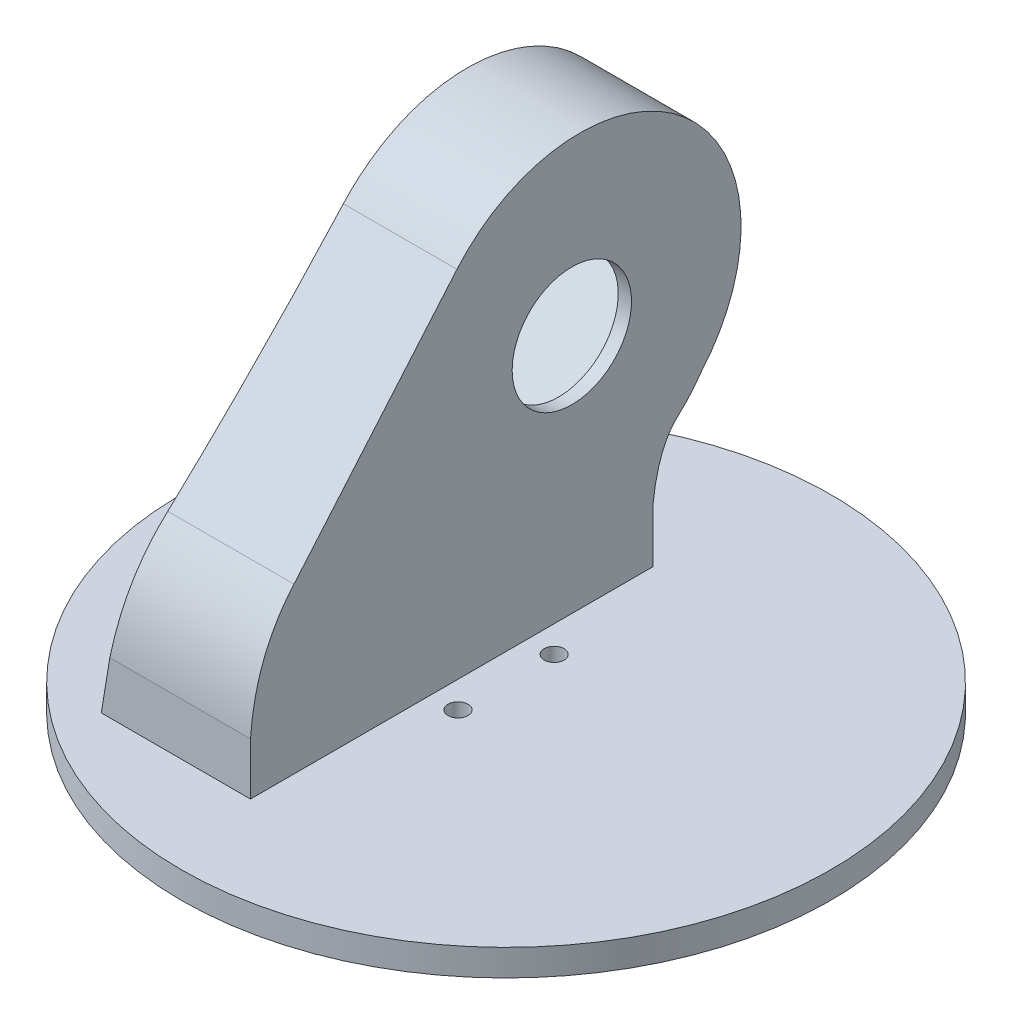
from build123d import *

# Parameters (mm, degrees)
CROQUIS1_R                 = 49
SALIENTE_EXTRUIR1_DEPTH    = 4
CROQUIS2_R                 = 1.5
CORTAR_EXTRUIR1_DEPTH      = 4
CROQUIS3_W                 = 22.5
CROQUIS3_H                 = 60.679
SALIENTE_EXTRUIR2_DEPTH    = 60.773
SALIENTE_EXTRUIR3_DEPTH    = 22.5
CORTAR_EXTRUIR2_DEPTH      = 22.5
CORTAR_EXTRUIR5_DEPTH      = 8.5
CORTAR_EXTRUIR6_DEPTH      = 29.5
CORTAR_EXTRUIR6_DEPTH_BACK = 78.5
CORTAR_EXTRUIR7_DEPTH      = 12
CORTAR_EXTRUIR8_REACH      = 57
CROQUIS12_R                = 9
CROQUIS13_R                = 1.3
CORTAR_EXTRUIR9_DEPTH      = 5
CROQUIS14_R                = 3.75
CORTAR_EXTRUIR10_DEPTH     = 2


with BuildPart() as part:
    # Croquis1 → Saliente-Extruir1 (new body)
    with BuildSketch(Plane(origin=(0, 0, 0), x_dir=(1, 0, 0), z_dir=(0, 1, 0))):
        Circle(CROQUIS1_R)
    extrude(amount=SALIENTE_EXTRUIR1_DEPTH)

    # Croquis2 → Cortar-Extruir1 (cut)
    with BuildSketch(Plane(origin=(0, 4, 0), x_dir=(1, 0, 0), z_dir=(0, 1, 0))):
        with Locations((0, 7.25)):
            Circle(CROQUIS2_R)
        with Locations((0, -7.25)):
            Circle(CROQUIS2_R)
    extrude(amount=-CORTAR_EXTRUIR1_DEPTH, mode=Mode.SUBTRACT)

    # Croquis3 → Saliente-Extruir2 (add)
    with BuildSketch(Plane(origin=(0, 4, 0), x_dir=(1, 0, 0), z_dir=(0, 1, 0))):
        with Locations((-15.25, -4.2105)):
            Rectangle(CROQUIS3_W, CROQUIS3_H)
    extrude(amount=SALIENTE_EXTRUIR2_DEPTH)

    # Croquis4 → Saliente-Extruir3 (add)
    with BuildSketch(Plane(origin=(-4, 0, 0), x_dir=(0, 0, -1), z_dir=(1, 0, 0))):
        with BuildLine():
            Line((-34.55, 4), (-34.55, 11.858))
            add(Edge.make_bspline(
                [(-34.55, 11.858), (-34.026556698, 21.514345964), (-28.575, 28.098)],
                knots=[0, 0, 0, 0.824435894, 0.824435894, 0.824435894], degree=2))
            Line((-28.575, 28.098), (-3.407, 57.621))
            ThreePointArc((-3.407, 57.621), (30.992681607, 60.270900315), (33.465, 25.858))
            add(Edge.make_bspline(
                [(29.748, 21.629), (31.899002628, 23.543234873), (33.465, 25.858)],
                knots=[0, 0, 0, 0.522921898, 0.522921898, 0.522921898], degree=2))
            add(Edge.make_bspline(
                [(26.129, 11.858), (26.849165043, 18.857512826), (29.748, 21.629)],
                knots=[0, 0, 0, 0.117772871, 0.117772871, 0.117772871], degree=2))
            Line((26.129, 11.858), (26.129, 4))
            Line((26.129, 4), (-34.55, 4))
        make_face()
    extrude(amount=-SALIENTE_EXTRUIR3_DEPTH)

    # Croquis5 → Cortar-Extruir2 (cut)
    with BuildSketch(Plane(origin=(-4, 0, 0), x_dir=(0, 0, -1), z_dir=(1, 0, 0))):
        with BuildLine():
            Line((-27.985060499, 28.790020974), (-3.407, 57.621))
            ThreePointArc((-3.407, 57.621), (1.319630754, 61.88266891), (6.989626025, 64.773))
            Line((6.989626025, 64.773), (-34.55, 64.773))
            Line((-34.55, 64.773), (-34.55, 11.858))
            add(Edge.make_bspline(
                [(-34.55, 11.858), (-34.095195054, 18.386707566), (-32.103528387, 23.800040899), (-28.575, 28.098)],
                knots=[0, 0, 0, 0, 0.605648705, 0.605648705, 0.605648705, 0.605648705], degree=3))
            add(Edge.make_bspline(
                [(-28.575, 28.098), (-28.382908254, 28.331979262), (-28.186261754, 28.56265292), (-27.985060499, 28.790020974)],
                knots=[0.605648705, 0.605648705, 0.605648705, 0.605648705, 0.638619991, 0.638619991, 0.638619991, 0.638619991], degree=3))
        make_face()
        with BuildLine():
            ThreePointArc((23.232314116, 64.773), (24.700788316, 64.198896251), (26.129, 63.530897014))
            Line((26.129, 63.530897014), (26.129, 64.773))
            Line((26.129, 64.773), (23.232314116, 64.773))
        make_face()
    extrude(amount=-CORTAR_EXTRUIR2_DEPTH, mode=Mode.SUBTRACT)

    # Croquis9 → Cortar-Extruir5 (cut)
    with BuildSketch(Plane.ZY.offset(26.5)):
        with BuildLine():
            Line((25.55, 4), (25.55, 7.838))
            add(Edge.make_bspline(
                [(25.55, 7.838), (24.886302853, 23.956871559), (17.259, 35.7)],
                knots=[0, 0, 0, 0.526933163, 0.526933163, 0.526933163], degree=2))
            add(Edge.make_bspline(
                [(17.259, 35.7), (14.834185302, 39.750302487), (11.753, 43.195)],
                knots=[0, 0, 0, 0.431108937, 0.431108937, 0.431108937], degree=2))
            Line((11.753, 43.195), (1.123987272, 55.674759295))
            ThreePointArc((1.123987272, 55.674759295), (-28.963418372, 57.90340371), (-31.192062787, 27.815998066))
            add(Edge.make_bspline(
                [(-15.129, 4), (-20.706034624, 17.629178957), (-31.192062787, 27.815998066)],
                knots=[0, 0, 0, 1, 1, 1], degree=2))
            Line((-15.129, 4), (25.55, 4))
        make_face()
    extrude(amount=-CORTAR_EXTRUIR5_DEPTH, mode=Mode.SUBTRACT)

    # Croquis10 → Cortar-Extruir6 (cut, two sides)
    with BuildSketch(Plane(origin=(0, 0, -26.129), x_dir=(-1, 0, 0), z_dir=(0, 0, -1))) as cortar_extruir6_sk:
        with BuildLine():
            Line((21, 66.168251112), (26.5, 66.168251112))
            Line((26.5, 66.168251112), (26.5, 4))
            add(Edge.make_bspline(
                [(21, 66.168251112), (21.140868098, 34.670825733), (26.5, 4)],
                knots=[0, 0, 0, 0.615166298, 0.615166298, 0.615166298], degree=2))
        make_face()
    extrude(amount=CORTAR_EXTRUIR6_DEPTH, mode=Mode.SUBTRACT)
    extrude(cortar_extruir6_sk.sketch, amount=-CORTAR_EXTRUIR6_DEPTH_BACK, mode=Mode.SUBTRACT)

    # Croquis11 → Cortar-Extruir7 (cut)
    with BuildSketch(Plane.ZY.offset(18)):
        Polygon((0.401, 11.108), (15.25, 25.957), (-13.741, 54.948), (-28.59, 40.099), align=None)
    extrude(amount=-CORTAR_EXTRUIR7_DEPTH, mode=Mode.SUBTRACT)

    # Croquis12 → Cortar-Extruir8 (cut, up to next)
    with BuildSketch(Plane.ZY.offset(6), mode=Mode.PRIVATE) as cortar_extruir8_sk1:
        with Locations((-13.918, 40.276)):
            Circle(CROQUIS12_R)
    cortar_extruir8_tool1 = extrude(cortar_extruir8_sk1.sketch, amount=-CORTAR_EXTRUIR8_REACH, mode=Mode.PRIVATE) & part.part
    add(cortar_extruir8_tool1.solids().sort_by_distance((-6, 40.276, -13.918))[0], mode=Mode.SUBTRACT)

    # Croquis13 → Cortar-Extruir9 (cut)
    with BuildSketch(Plane.ZY.offset(18)):
        with Locations((-27.176836773, 46.464011366)):
            Circle(CROQUIS13_R)
        with Locations((-20.104694437, 53.533519844)):
            Circle(CROQUIS13_R)
        with Locations((6.766011366, 12.521163227)):
            Circle(CROQUIS13_R)
        with Locations((13.836836773, 19.591988634)):
            Circle(CROQUIS13_R)
    extrude(amount=-CORTAR_EXTRUIR9_DEPTH, mode=Mode.SUBTRACT)

    # Croquis14 → Cortar-Extruir10 (cut)
    with BuildSketch(Plane.XZ):
        Circle(CROQUIS14_R)
    extrude(amount=-CORTAR_EXTRUIR10_DEPTH, mode=Mode.SUBTRACT)


solid = part.part
